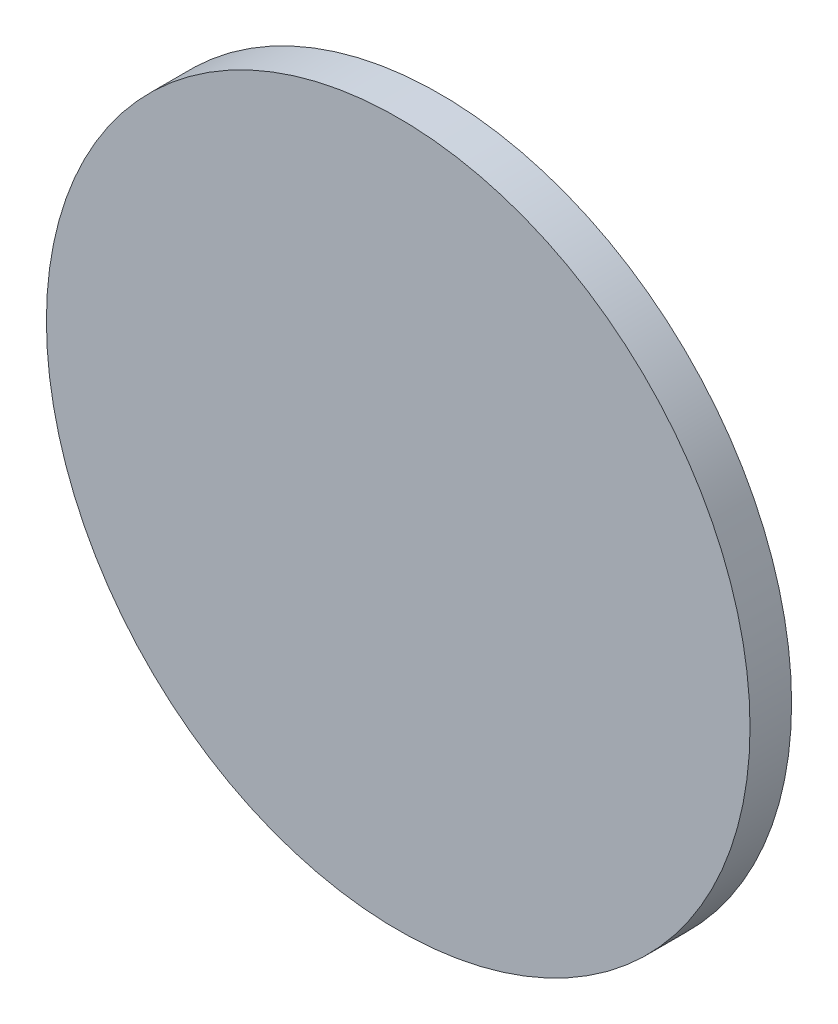
from build123d import *

# Parameters (mm, degrees)
SKETCH1_R           = 25.4
BOSS_EXTRUDE1_DEPTH = 3


with BuildPart() as part:
    # Sketch1 → Boss-Extrude1 (new body)
    with BuildSketch(Plane.XY):
        Circle(SKETCH1_R)
    extrude(amount=BOSS_EXTRUDE1_DEPTH)


solid = part.part
